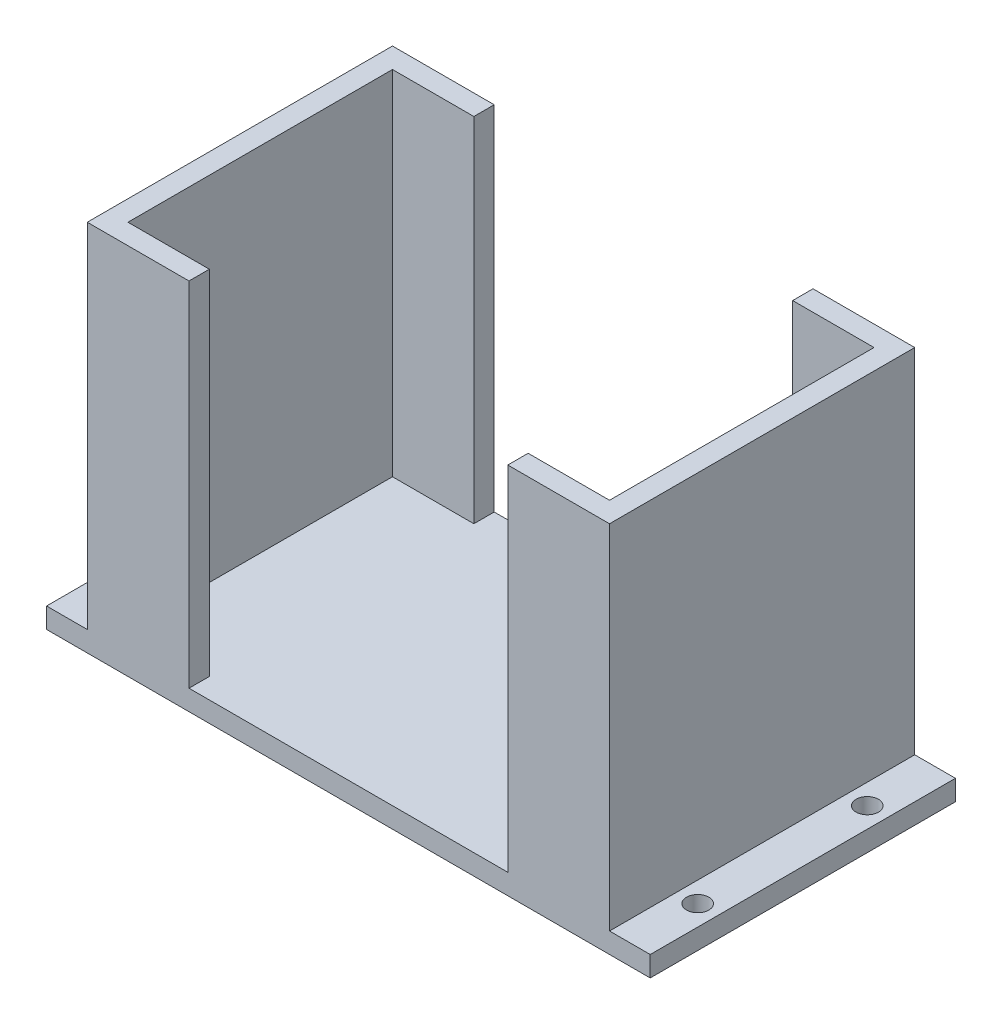
from build123d import *

# Parameters (mm, degrees)
EXTRUDE_1_DEPTH     = 55
SKETCH_3_W          = 47
SKETCH_3_H          = 3
EXTRUDE_2_DEPTH     = 3
SKETCH_4_W          = 45
SKETCH_4_H          = 3
EXTRUDE_3_DEPTH     = 6
SKETCH_6_R          = 1.65
CUT_EXTRUDE_1_DEPTH = 6
SKETCH_7_W          = 45
SKETCH_7_H          = 3
EXTRUDE_4_DEPTH     = 6
SKETCH_8_R          = 1.65
CUT_EXTRUDE_2_DEPTH = 6


with BuildPart() as part:
    # 草图1 → 凸台-拉伸1 (new body)
    with BuildSketch(Plane(origin=(0, 0, 0), x_dir=(1, 0, 0), z_dir=(0, 1, 0))):
        Polygon((-38.5, 0), (-35.5, 0), (-35.5, 19.5), (-23.5, 19.5), (-23.5, 22.5), (-38.5, 22.5), align=None)
        Polygon((-35.5, -19.5), (-35.5, 0), (-38.5, 0), (-38.5, -22.5), (-23.5, -22.5), (-23.5, -19.5), align=None)
        Polygon((23.5, 22.5), (23.5, 19.5), (35.5, 19.5), (35.5, -19.5), (23.5, -19.5), (23.5, -22.5), (38.5, -22.5), (38.5, 22.5), align=None)
    extrude(amount=EXTRUDE_1_DEPTH)

    # 草图3 → 凸台-拉伸2 (add)
    with BuildSketch(Plane.XZ):
        with Locations((0, 21)):
            Rectangle(SKETCH_3_W, SKETCH_3_H)
        Polygon((-35.5, 19.5), (-35.5, -19.5), (-23.5, -19.5), (23.5, -19.5), (35.5, -19.5), (35.5, 19.5), (23.5, 19.5), (-23.5, 19.5), align=None)
        with Locations((0, -21)):
            Rectangle(SKETCH_3_W, SKETCH_3_H)
    extrude(amount=-EXTRUDE_2_DEPTH)

    # 草图4 → 凸台-拉伸3 (add)
    with BuildSketch(Plane(origin=(38.5, 0, 0), x_dir=(0, 0, -1), z_dir=(1, 0, 0))):
        with Locations((0, 1.5)):
            Rectangle(SKETCH_4_W, SKETCH_4_H)
    extrude(amount=EXTRUDE_3_DEPTH)

    # 草图6 → 切除-拉伸1 (cut)
    with BuildSketch(Plane(origin=(0, 3, 0), x_dir=(1, 0, 0), z_dir=(0, 1, 0))):
        with Locations((41.5, -12.5)):
            Circle(SKETCH_6_R)
        with Locations((41.5, 12.5)):
            Circle(SKETCH_6_R)
    extrude(amount=-CUT_EXTRUDE_1_DEPTH, mode=Mode.SUBTRACT)

    # 草图7 → 凸台-拉伸4 (add)
    with BuildSketch(Plane.ZY.offset(38.5)):
        with Locations((0, 1.5)):
            Rectangle(SKETCH_7_W, SKETCH_7_H)
    extrude(amount=EXTRUDE_4_DEPTH)

    # 草图8 → 切除-拉伸2 (cut)
    with BuildSketch(Plane(origin=(0, 3, 0), x_dir=(1, 0, 0), z_dir=(0, 1, 0))):
        with Locations((-41.5, 12.5)):
            Circle(SKETCH_8_R)
        with Locations((-41.5, -12.5)):
            Circle(SKETCH_8_R)
    extrude(amount=-CUT_EXTRUDE_2_DEPTH, mode=Mode.SUBTRACT)


solid = part.part
